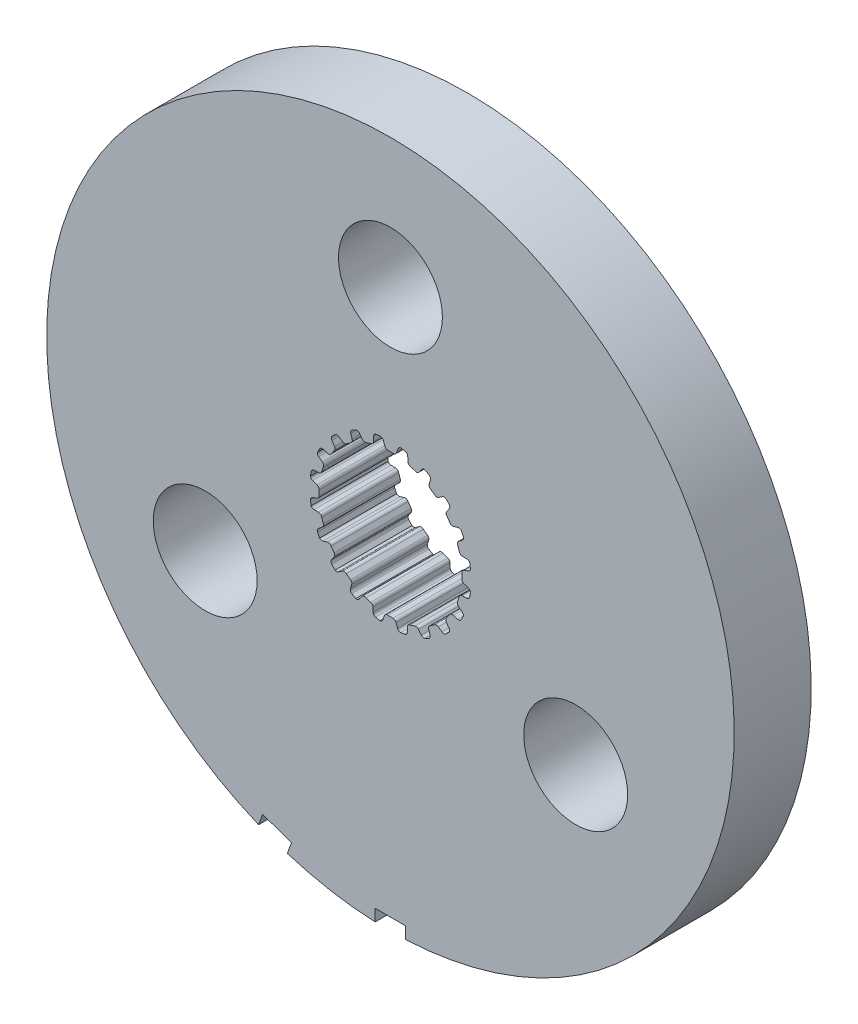
from build123d import *

# Parameters (mm, degrees)
SKETCH1_R           = 14.2875
BOSS_EXTRUDE1_DEPTH = 3.2004
SKETCH5_R           = 2.159
CUT_EXTRUDE2_DEPTH  = 3.2004
SKETCH7_W           = 1.27
SKETCH7_H           = 0.508
CUT_EXTRUDE3_DEPTH  = 3.2004


with BuildPart() as part:
    # Sketch1 → Boss-Extrude1 (new body)
    with BuildSketch(Plane.XY):
        Circle(SKETCH1_R)
        with BuildLine():
            Line((-0.106949245, 2.969874934), (0.106949245, 2.969874934))
            ThreePointArc((0.106949245, 2.969874934), (0.196343213, 2.986924176), (0.253739238, 3.057547504))
            Line((0.253739238, 3.057547504), (0.315888147, 3.237526941))
            ThreePointArc((0.315888147, 3.237526941), (0.359032156, 3.298322911), (0.4281449, 3.326269005))
            Line((0.4281449, 3.326269005), (0.620027588, 3.2937547))
            ThreePointArc((0.620027588, 3.2937547), (0.689621142, 3.24802576), (0.718272212, 3.169836791))
            Line((0.718272212, 3.169836791), (0.724389167, 2.979527391))
            ThreePointArc((0.724389167, 2.979527391), (0.750934762, 2.9040661), (0.816027049, 2.857568043))
            Line((0.816027049, 2.857568043), (1.019456602, 2.791469774))
            ThreePointArc((1.019456602, 2.791469774), (1.109743823, 2.780060312), (1.186154496, 2.829490741))
            Line((1.186154496, 2.829490741), (1.300878326, 2.981456288))
            ThreePointArc((1.300878326, 2.981456288), (1.360697704, 3.02594446), (1.435063648, 3.031165762))
            Line((1.435063648, 3.031165762), (1.607507455, 2.940947809))
            ThreePointArc((1.607507455, 2.940947809), (1.659563839, 2.875951412), (1.662650905, 2.792735615))
            Line((1.662650905, 2.792735615), (1.609659636, 2.609850378))
            ThreePointArc((1.609659636, 2.609850378), (1.611587176, 2.529879385), (1.659124931, 2.465542482))
            Line((1.659124931, 2.465542482), (1.832172444, 2.339816104))
            ThreePointArc((1.832172444, 2.339816104), (1.914514976, 2.301064775), (2.002460687, 2.32446371))
            Line((2.002460687, 2.32446371), (2.158529469, 2.433539921))
            ThreePointArc((2.158529469, 2.433539921), (2.229168681, 2.457365482), (2.301508367, 2.439350895))
            Line((2.301508367, 2.439350895), (2.437633293, 2.300260456))
            ThreePointArc((2.437633293, 2.300260456), (2.467056864, 2.222358901), (2.444277744, 2.14226202))
            Line((2.444277744, 2.14226202), (2.337365406, 1.984703026))
            ThreePointArc((2.337365406, 1.984703026), (2.314486209, 1.908050449), (2.339816104, 1.832172444))
            Line((2.339816104, 1.832172444), (2.465542482, 1.659124931))
            ThreePointArc((2.465542482, 1.659124931), (2.531880064, 1.596824985), (2.622752074, 1.591901975))
            Line((2.622752074, 1.591901975), (2.804888709, 1.64741171))
            ThreePointArc((2.804888709, 1.64741171), (2.879433095, 1.648242449), (2.942665411, 1.608755366))
            Line((2.942665411, 1.608755366), (3.0291466, 1.434407582))
            ThreePointArc((3.0291466, 1.434407582), (3.033057175, 1.351226417), (2.986641646, 1.282088892))
            Line((2.986641646, 1.282088892), (2.836273564, 1.165279113))
            ThreePointArc((2.836273564, 1.165279113), (2.790827206, 1.099448241), (2.791469774, 1.019456602))
            Line((2.791469774, 1.019456602), (2.857568043, 0.816027049))
            ThreePointArc((2.857568043, 0.816027049), (2.901407091, 0.736276839), (2.986310214, 0.703513784))
            Line((2.986310214, 0.703513784), (3.1766859, 0.700023363))
            ThreePointArc((3.1766859, 0.700023363), (3.247838536, 0.677777961), (3.295773863, 0.620683653))
            Line((3.295773863, 0.620683653), (3.324145932, 0.4281449))
            ThreePointArc((3.324145932, 0.4281449), (3.302160717, 0.347826477), (3.236652255, 0.29641597))
            Line((3.236652255, 0.29641597), (3.057547504, 0.231789562))
            ThreePointArc((3.057547504, 0.231789562), (2.993982591, 0.183224379), (2.969874934, 0.106949245))
            Line((2.969874934, 0.106949245), (2.969874934, -0.106949245))
            ThreePointArc((2.969874934, -0.106949245), (2.986924176, -0.196343213), (3.057547504, -0.253739238))
            Line((3.057547504, -0.253739238), (3.237526941, -0.315888147))
            ThreePointArc((3.237526941, -0.315888147), (3.298322911, -0.359032156), (3.326269005, -0.4281449))
            Line((3.326269005, -0.4281449), (3.2937547, -0.620027588))
            ThreePointArc((3.2937547, -0.620027588), (3.24802576, -0.689621142), (3.169836791, -0.718272212))
            Line((3.169836791, -0.718272212), (2.979527391, -0.724389167))
            ThreePointArc((2.979527391, -0.724389167), (2.9040661, -0.750934762), (2.857568043, -0.816027049))
            Line((2.857568043, -0.816027049), (2.791469774, -1.019456602))
            ThreePointArc((2.791469774, -1.019456602), (2.780060312, -1.109743823), (2.829490741, -1.186154496))
            Line((2.829490741, -1.186154496), (2.981456288, -1.300878326))
            ThreePointArc((2.981456288, -1.300878326), (3.02594446, -1.360697704), (3.031165762, -1.435063648))
            Line((3.031165762, -1.435063648), (2.940947809, -1.607507455))
            ThreePointArc((2.940947809, -1.607507455), (2.875951412, -1.659563839), (2.792735615, -1.662650905))
            Line((2.792735615, -1.662650905), (2.609850378, -1.609659636))
            ThreePointArc((2.609850378, -1.609659636), (2.529879385, -1.611587176), (2.465542482, -1.659124931))
            Line((2.465542482, -1.659124931), (2.339816104, -1.832172444))
            ThreePointArc((2.339816104, -1.832172444), (2.301064775, -1.914514976), (2.32446371, -2.002460687))
            Line((2.32446371, -2.002460687), (2.433539921, -2.158529469))
            ThreePointArc((2.433539921, -2.158529469), (2.457365482, -2.229168681), (2.439350895, -2.301508367))
            Line((2.439350895, -2.301508367), (2.300260456, -2.437633293))
            ThreePointArc((2.300260456, -2.437633293), (2.222358901, -2.467056864), (2.14226202, -2.444277744))
            Line((2.14226202, -2.444277744), (1.984703026, -2.337365406))
            ThreePointArc((1.984703026, -2.337365406), (1.908050449, -2.314486209), (1.832172444, -2.339816104))
            Line((1.832172444, -2.339816104), (1.659124931, -2.465542482))
            ThreePointArc((1.659124931, -2.465542482), (1.596824985, -2.531880064), (1.591901975, -2.622752074))
            Line((1.591901975, -2.622752074), (1.64741171, -2.804888709))
            ThreePointArc((1.64741171, -2.804888709), (1.648242449, -2.879433095), (1.608755366, -2.942665411))
            Line((1.608755366, -2.942665411), (1.434407582, -3.0291466))
            ThreePointArc((1.434407582, -3.0291466), (1.351226417, -3.033057175), (1.282088892, -2.986641646))
            Line((1.282088892, -2.986641646), (1.165279113, -2.836273564))
            ThreePointArc((1.165279113, -2.836273564), (1.099448241, -2.790827206), (1.019456602, -2.791469774))
            Line((1.019456602, -2.791469774), (0.816027049, -2.857568043))
            ThreePointArc((0.816027049, -2.857568043), (0.736276839, -2.901407091), (0.703513784, -2.986310214))
            Line((0.703513784, -2.986310214), (0.700023363, -3.1766859))
            ThreePointArc((0.700023363, -3.1766859), (0.677777961, -3.247838536), (0.620683653, -3.295773863))
            Line((0.620683653, -3.295773863), (0.4281449, -3.324145932))
            ThreePointArc((0.4281449, -3.324145932), (0.347826477, -3.302160717), (0.29641597, -3.236652255))
            Line((0.29641597, -3.236652255), (0.231789562, -3.057547504))
            ThreePointArc((0.231789562, -3.057547504), (0.183224379, -2.993982591), (0.106949245, -2.969874934))
            Line((0.106949245, -2.969874934), (-0.106949245, -2.969874934))
            ThreePointArc((-0.106949245, -2.969874934), (-0.196343213, -2.986924176), (-0.253739238, -3.057547504))
            Line((-0.253739238, -3.057547504), (-0.315888147, -3.237526941))
            ThreePointArc((-0.315888147, -3.237526941), (-0.359032156, -3.298322911), (-0.4281449, -3.326269005))
            Line((-0.4281449, -3.326269005), (-0.620027588, -3.2937547))
            ThreePointArc((-0.620027588, -3.2937547), (-0.689621142, -3.24802576), (-0.718272212, -3.169836791))
            Line((-0.718272212, -3.169836791), (-0.724389167, -2.979527391))
            ThreePointArc((-0.724389167, -2.979527391), (-0.750934762, -2.9040661), (-0.816027049, -2.857568043))
            Line((-0.816027049, -2.857568043), (-1.019456602, -2.791469774))
            ThreePointArc((-1.019456602, -2.791469774), (-1.109743823, -2.780060312), (-1.186154496, -2.829490741))
            Line((-1.186154496, -2.829490741), (-1.300878326, -2.981456288))
            ThreePointArc((-1.300878326, -2.981456288), (-1.360697704, -3.02594446), (-1.435063648, -3.031165762))
            Line((-1.435063648, -3.031165762), (-1.607507455, -2.940947809))
            ThreePointArc((-1.607507455, -2.940947809), (-1.659563839, -2.875951412), (-1.662650905, -2.792735615))
            Line((-1.662650905, -2.792735615), (-1.609659636, -2.609850378))
            ThreePointArc((-1.609659636, -2.609850378), (-1.611587176, -2.529879385), (-1.659124931, -2.465542482))
            Line((-1.659124931, -2.465542482), (-1.832172444, -2.339816104))
            ThreePointArc((-1.832172444, -2.339816104), (-1.914514976, -2.301064775), (-2.002460687, -2.32446371))
            Line((-2.002460687, -2.32446371), (-2.158529469, -2.433539921))
            ThreePointArc((-2.158529469, -2.433539921), (-2.229168681, -2.457365482), (-2.301508367, -2.439350895))
            Line((-2.301508367, -2.439350895), (-2.437633293, -2.300260456))
            ThreePointArc((-2.437633293, -2.300260456), (-2.467056864, -2.222358901), (-2.444277744, -2.14226202))
            Line((-2.444277744, -2.14226202), (-2.337365406, -1.984703026))
            ThreePointArc((-2.337365406, -1.984703026), (-2.314486209, -1.908050449), (-2.339816104, -1.832172444))
            Line((-2.339816104, -1.832172444), (-2.465542482, -1.659124931))
            ThreePointArc((-2.465542482, -1.659124931), (-2.531880064, -1.596824985), (-2.622752074, -1.591901975))
            Line((-2.622752074, -1.591901975), (-2.804888709, -1.64741171))
            ThreePointArc((-2.804888709, -1.64741171), (-2.879433095, -1.648242449), (-2.942665411, -1.608755366))
            Line((-2.942665411, -1.608755366), (-3.0291466, -1.434407582))
            ThreePointArc((-3.0291466, -1.434407582), (-3.033057175, -1.351226417), (-2.986641646, -1.282088892))
            Line((-2.986641646, -1.282088892), (-2.836273564, -1.165279113))
            ThreePointArc((-2.836273564, -1.165279113), (-2.790827206, -1.099448241), (-2.791469774, -1.019456602))
            Line((-2.791469774, -1.019456602), (-2.857568043, -0.816027049))
            ThreePointArc((-2.857568043, -0.816027049), (-2.901407091, -0.736276839), (-2.986310214, -0.703513784))
            Line((-2.986310214, -0.703513784), (-3.1766859, -0.700023363))
            ThreePointArc((-3.1766859, -0.700023363), (-3.247838536, -0.677777961), (-3.295773863, -0.620683653))
            Line((-3.295773863, -0.620683653), (-3.324145932, -0.4281449))
            ThreePointArc((-3.324145932, -0.4281449), (-3.302160717, -0.347826477), (-3.236652255, -0.29641597))
            Line((-3.236652255, -0.29641597), (-3.057547504, -0.231789562))
            ThreePointArc((-3.057547504, -0.231789562), (-2.993982591, -0.183224379), (-2.969874934, -0.106949245))
            Line((-2.969874934, -0.106949245), (-2.969874934, 0.106949245))
            ThreePointArc((-2.969874934, 0.106949245), (-2.986924176, 0.196343213), (-3.057547504, 0.253739238))
            Line((-3.057547504, 0.253739238), (-3.237526941, 0.315888147))
            ThreePointArc((-3.237526941, 0.315888147), (-3.298322911, 0.359032156), (-3.326269005, 0.4281449))
            Line((-3.326269005, 0.4281449), (-3.2937547, 0.620027588))
            ThreePointArc((-3.2937547, 0.620027588), (-3.24802576, 0.689621142), (-3.169836791, 0.718272212))
            Line((-3.169836791, 0.718272212), (-2.979527391, 0.724389167))
            ThreePointArc((-2.979527391, 0.724389167), (-2.9040661, 0.750934762), (-2.857568043, 0.816027049))
            Line((-2.857568043, 0.816027049), (-2.791469774, 1.019456602))
            ThreePointArc((-2.791469774, 1.019456602), (-2.780060312, 1.109743823), (-2.829490741, 1.186154496))
            Line((-2.829490741, 1.186154496), (-2.981456288, 1.300878326))
            ThreePointArc((-2.981456288, 1.300878326), (-3.02594446, 1.360697704), (-3.031165762, 1.435063648))
            Line((-3.031165762, 1.435063648), (-2.940947809, 1.607507455))
            ThreePointArc((-2.940947809, 1.607507455), (-2.875951412, 1.659563839), (-2.792735615, 1.662650905))
            Line((-2.792735615, 1.662650905), (-2.609850378, 1.609659636))
            ThreePointArc((-2.609850378, 1.609659636), (-2.529879385, 1.611587176), (-2.465542482, 1.659124931))
            Line((-2.465542482, 1.659124931), (-2.339816104, 1.832172444))
            ThreePointArc((-2.339816104, 1.832172444), (-2.301064775, 1.914514976), (-2.32446371, 2.002460687))
            Line((-2.32446371, 2.002460687), (-2.433539921, 2.158529469))
            ThreePointArc((-2.433539921, 2.158529469), (-2.457365482, 2.229168681), (-2.439350895, 2.301508367))
            Line((-2.439350895, 2.301508367), (-2.300260456, 2.437633293))
            ThreePointArc((-2.300260456, 2.437633293), (-2.222358901, 2.467056864), (-2.14226202, 2.444277744))
            Line((-2.14226202, 2.444277744), (-1.984703026, 2.337365406))
            ThreePointArc((-1.984703026, 2.337365406), (-1.908050449, 2.314486209), (-1.832172444, 2.339816104))
            Line((-1.832172444, 2.339816104), (-1.659124931, 2.465542482))
            ThreePointArc((-1.659124931, 2.465542482), (-1.596824985, 2.531880064), (-1.591901975, 2.622752074))
            Line((-1.591901975, 2.622752074), (-1.64741171, 2.804888709))
            ThreePointArc((-1.64741171, 2.804888709), (-1.648242449, 2.879433095), (-1.608755366, 2.942665411))
            Line((-1.608755366, 2.942665411), (-1.434407582, 3.0291466))
            ThreePointArc((-1.434407582, 3.0291466), (-1.351226417, 3.033057175), (-1.282088892, 2.986641646))
            Line((-1.282088892, 2.986641646), (-1.165279113, 2.836273564))
            ThreePointArc((-1.165279113, 2.836273564), (-1.099448241, 2.790827206), (-1.019456602, 2.791469774))
            Line((-1.019456602, 2.791469774), (-0.816027049, 2.857568043))
            ThreePointArc((-0.816027049, 2.857568043), (-0.736276839, 2.901407091), (-0.703513784, 2.986310214))
            Line((-0.703513784, 2.986310214), (-0.700023363, 3.1766859))
            ThreePointArc((-0.700023363, 3.1766859), (-0.677777961, 3.247838536), (-0.620683653, 3.295773863))
            Line((-0.620683653, 3.295773863), (-0.4281449, 3.324145932))
            ThreePointArc((-0.4281449, 3.324145932), (-0.347826477, 3.302160717), (-0.29641597, 3.236652255))
            Line((-0.29641597, 3.236652255), (-0.231789562, 3.057547504))
            ThreePointArc((-0.231789562, 3.057547504), (-0.183224379, 2.993982591), (-0.106949245, 2.969874934))
        make_face(mode=Mode.SUBTRACT)
    extrude(amount=BOSS_EXTRUDE1_DEPTH)

    # Sketch5 → Cut-Extrude2 (cut)
    with BuildSketch(Plane.XY.offset(3.2004)):
        with Locations((0, 8.89)):
            Circle(SKETCH5_R)
        with Locations((7.69896584, -4.445)):
            Circle(SKETCH5_R)
        with Locations((-7.69896584, -4.445)):
            Circle(SKETCH5_R)
    extrude(amount=-CUT_EXTRUDE2_DEPTH, mode=Mode.SUBTRACT)

    # Sketch7 → Cut-Extrude3 (cut)
    with BuildSketch(Plane.XY.offset(3.2004)):
        Polygon((-4.289907984, -13.64304111), (-4.116161751, -13.165677259), (-5.309571379, -12.731311677), (-5.483317612, -13.208675528), align=None)
        with Locations((0, -14.0335)):
            Rectangle(SKETCH7_W, SKETCH7_H)
    extrude(amount=-CUT_EXTRUDE3_DEPTH, mode=Mode.SUBTRACT)


solid = part.part
